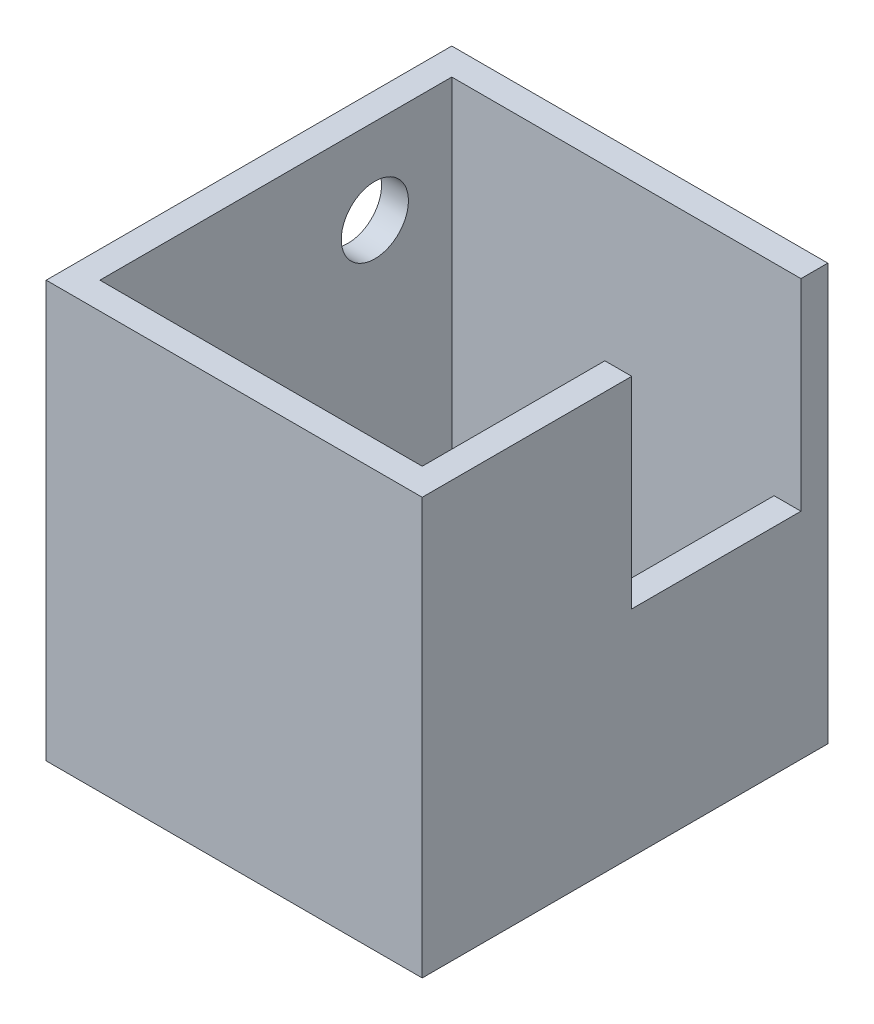
from build123d import *

# Parameters (mm, degrees)
ESQUISSE1_W             = 28
ESQUISSE1_H             = 31
BOSS_EXTRU_1_DEPTH      = 30.2
COQUE1_T                = -2
ENL_V_MAT_EXTRU_1_REACH = 30
ESQUISSE2_W             = 12.6
ESQUISSE2_H             = 15
ENL_V_MAT_EXTRU_2_REACH = 4
ESQUISSE3_W             = 15
ESQUISSE3_H             = 12.6
ESQUISSE4_W             = 24
ESQUISSE4_H             = 12.6
BOSS_EXTRU_2_DEPTH      = 1.5
ENL_V_MAT_EXTRU_4_REACH = 30
ESQUISSE10_R            = 2.5


with BuildPart() as part:
    # Esquisse1 → Boss.-Extru.1 (new body)
    with BuildSketch(Plane.XY):
        with Locations((14, 15.5)):
            Rectangle(ESQUISSE1_W, ESQUISSE1_H)
    extrude(amount=BOSS_EXTRU_1_DEPTH)

    # Coque1
    coque1_openings = [part.faces().sort_by_distance(p)[0] for p in [
        (14, 31, 15.1),
    ]]
    offset(amount=COQUE1_T, openings=coque1_openings, kind=Kind.INTERSECTION)

    # Esquisse2 → Enlèv. mat.-Extru.1 (cut, up to next)
    with BuildSketch(Plane(origin=(28, 0, 0), x_dir=(0, 0, -1), z_dir=(1, 0, 0)), mode=Mode.PRIVATE) as enl_v_mat_extru_1_sk1:
        with Locations((-8.3, 23.5)):
            Rectangle(ESQUISSE2_W, ESQUISSE2_H)
    enl_v_mat_extru_1_tool1 = extrude(enl_v_mat_extru_1_sk1.sketch, amount=-ENL_V_MAT_EXTRU_1_REACH, mode=Mode.PRIVATE) & part.part
    add(enl_v_mat_extru_1_tool1.solids().sort_by_distance((28, 23.5, 8.3))[0], mode=Mode.SUBTRACT)

    # Esquisse3 → Enlèv. mat.-Extru.2 (cut, up to next)
    with BuildSketch(Plane(origin=(0, 2, 0), x_dir=(1, 0, 0), z_dir=(0, 1, 0)), mode=Mode.PRIVATE) as enl_v_mat_extru_2_sk1:
        with Locations((9.5, -21.9)):
            Rectangle(ESQUISSE3_W, ESQUISSE3_H)
    enl_v_mat_extru_2_tool1 = extrude(enl_v_mat_extru_2_sk1.sketch, amount=-ENL_V_MAT_EXTRU_2_REACH, mode=Mode.PRIVATE) & part.part
    add(enl_v_mat_extru_2_tool1.solids().sort_by_distance((9.5, 2, 21.9))[0], mode=Mode.SUBTRACT)

    # Esquisse4 → Boss.-Extru.2 (add)
    with BuildSketch(Plane(origin=(0, 2, 0), x_dir=(1, 0, 0), z_dir=(0, 1, 0))):
        with Locations((14, -8.3)):
            Rectangle(ESQUISSE4_W, ESQUISSE4_H)
    extrude(amount=BOSS_EXTRU_2_DEPTH)

    # Esquisse10 → Enlèv. mat.-Extru.4 (cut, up to next)
    with BuildSketch(Plane.ZY, mode=Mode.PRIVATE) as enl_v_mat_extru_4_sk1:
        with Locations((7.728265811, 24.64)):
            Circle(ESQUISSE10_R)
    enl_v_mat_extru_4_tool1 = extrude(enl_v_mat_extru_4_sk1.sketch, amount=-ENL_V_MAT_EXTRU_4_REACH, mode=Mode.PRIVATE) & part.part
    add(enl_v_mat_extru_4_tool1.solids().sort_by_distance((0, 24.64, 7.728266))[0], mode=Mode.SUBTRACT)


solid = part.part
